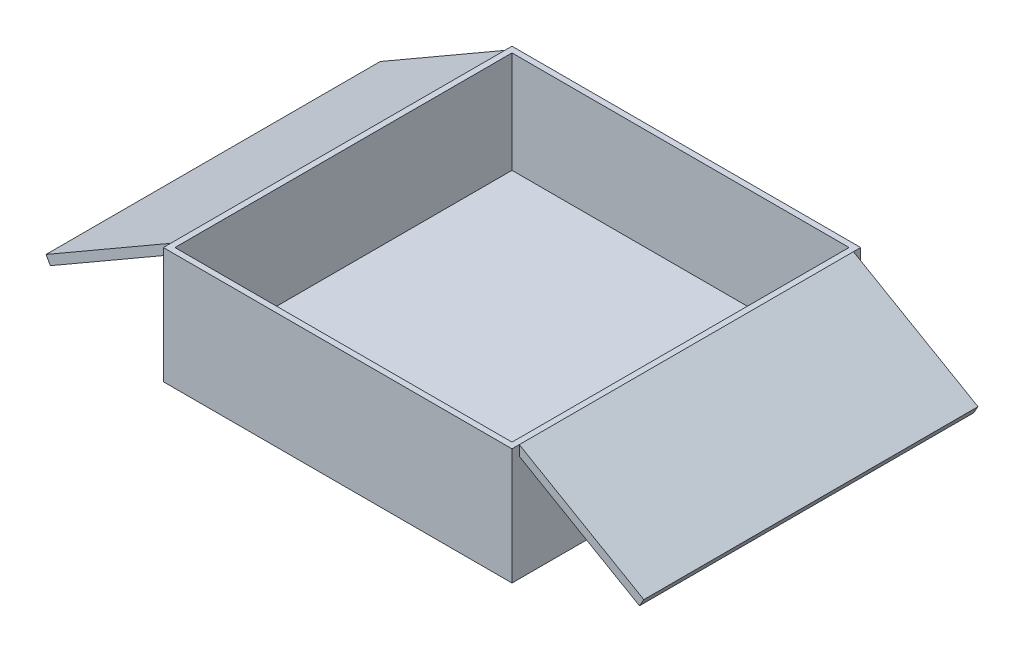
from build123d import *

# Parameters (mm, degrees)
SKETCH1_W           = 120
SKETCH1_H           = 120
BOSS_EXTRUDE1_DEPTH = 5
SKETCH1_3_W         = 120
SKETCH1_3_H         = 120
SKETCH1_3_W_2       = 116
SKETCH1_3_H_2       = 116
BOSS_EXTRUDE2_DEPTH = 40
BOSS_EXTRUDE3_DEPTH = 57.5


with BuildPart() as part:
    # Sketch1 → Boss-Extrude1 (new body)
    with BuildSketch(Plane(origin=(0, 0, 0), x_dir=(1, 0, 0), z_dir=(0, 1, 0))):
        Rectangle(SKETCH1_W, SKETCH1_H)
    extrude(amount=BOSS_EXTRUDE1_DEPTH)

    # Sketch1_3 → Boss-Extrude2 (add)
    with BuildSketch(Plane(origin=(0, 0, 0), x_dir=(1, 0, 0), z_dir=(0, 1, 0))):
        Rectangle(SKETCH1_3_W, SKETCH1_3_H)
        Rectangle(SKETCH1_3_W_2, SKETCH1_3_H_2, mode=Mode.SUBTRACT)
    extrude(amount=BOSS_EXTRUDE2_DEPTH)

    # Sketch2 → Boss-Extrude3 (add, symmetric)
    with BuildSketch(Plane.XY):
        Polygon((60, 40), (102.868257487, 15.25), (101.368257487, 12.651923789), (60, 36.535898385), align=None)
    boss_extrude3 = extrude(amount=BOSS_EXTRUDE3_DEPTH, both=True)

    # Mirror1: Boss-Extrude3 across plane
    add(boss_extrude3.mirror(Plane(origin=(0, 0, 0), x_dir=(0, 0, 1), z_dir=(1, 0, 0))))


solid = part.part
